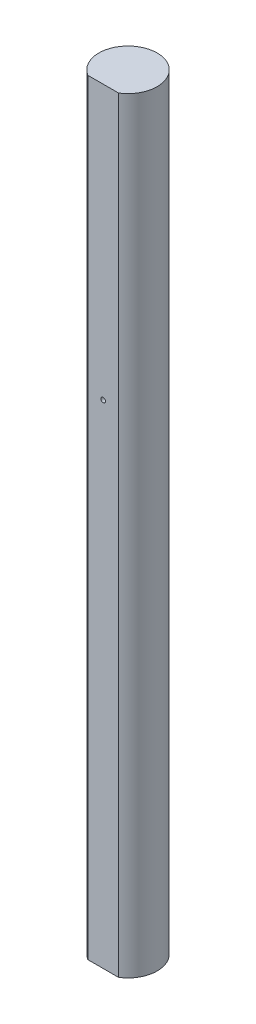
from build123d import *

# Parameters (mm, degrees)
BOSS_EXTRUDE1_DEPTH       = 500
SKETCH5_R                 = 1.5
CUT_EXTRUDE1_DEPTH        = 5
M5X0_8_TAPPED_HOLE1_D     = 4.2
M5X0_8_TAPPED_HOLE1_DEPTH = 10
M5X0_8_TAPPED_HOLE1_TIP   = 1.2618073


with BuildPart() as part:
    # Sketch3 → Boss-Extrude1 (new body)
    with BuildSketch(Plane(origin=(0, 0, 0), x_dir=(1, 0, 0), z_dir=(0, 1, 0))):
        with BuildLine():
            Line((-10, -16.214268408), (10, -16.214268408))
            ThreePointArc((10, -16.214268408), (0, 19.05), (-10, -16.214268408))
        make_face()
    extrude(amount=BOSS_EXTRUDE1_DEPTH)

    # Sketch5 → Cut-Extrude1 (cut)
    with BuildSketch(Plane.XY.offset(16.214268408)):
        with Locations((0, 321.4)):
            Circle(SKETCH5_R)
    extrude(amount=-CUT_EXTRUDE1_DEPTH, mode=Mode.SUBTRACT)

    # M5x0.8 Tapped Hole1
    with Locations(Plane(origin=(0, 0, 0), x_dir=(-1, 0, 0), z_dir=(0, -1, 0))):
        with Locations((0, 0)):
            Hole(M5X0_8_TAPPED_HOLE1_D / 2, depth=M5X0_8_TAPPED_HOLE1_DEPTH)
            with Locations((0, 0, -(M5X0_8_TAPPED_HOLE1_DEPTH + M5X0_8_TAPPED_HOLE1_TIP / 2))):  # 118° drill point
                Cone(0, M5X0_8_TAPPED_HOLE1_D / 2, M5X0_8_TAPPED_HOLE1_TIP, mode=Mode.SUBTRACT)


solid = part.part
